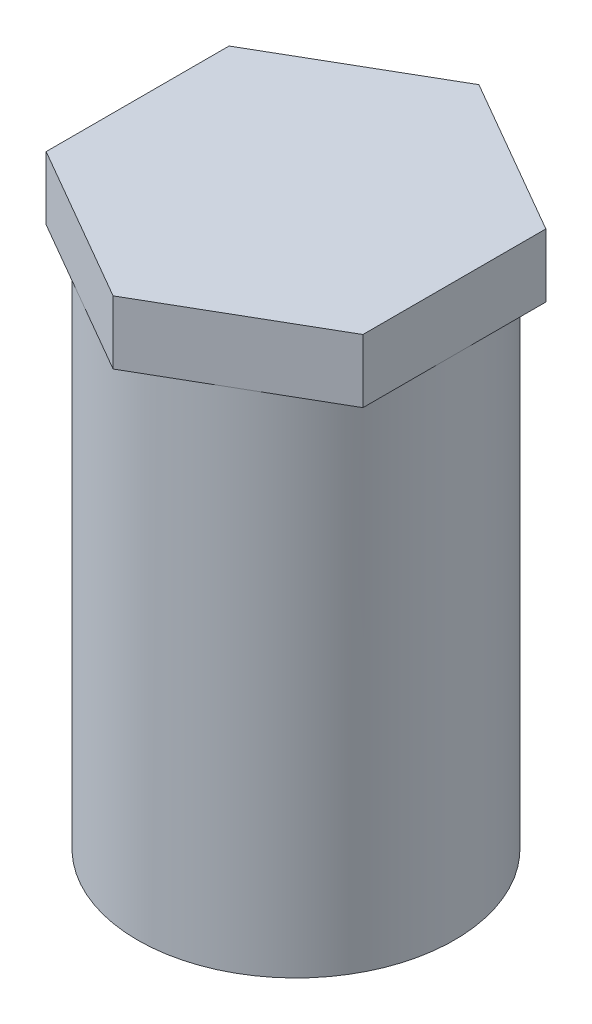
from build123d import *

# Parameters (mm, degrees)
SKETCH1_R           = 12.5
BOSS_EXTRUDE1_DEPTH = 40
BOSS_EXTRUDE2_DEPTH = 5


with BuildPart() as part:
    # Sketch1 → Boss-Extrude1 (new body)
    with BuildSketch(Plane(origin=(0, 0, 0), x_dir=(1, 0, 0), z_dir=(0, 1, 0))):
        Circle(SKETCH1_R)
    extrude(amount=BOSS_EXTRUDE1_DEPTH)

    # Sketch2 → Boss-Extrude2 (add)
    with BuildSketch(Plane(origin=(0, 40, 0), x_dir=(1, 0, 0), z_dir=(0, 1, 0))):
        Polygon((0, -14.43375673), (12.5, -7.216878365), (12.5, 7.216878365), (0, 14.43375673), (-12.5, 7.216878365), (-12.5, -7.216878365), align=None)
    extrude(amount=BOSS_EXTRUDE2_DEPTH)


solid = part.part
